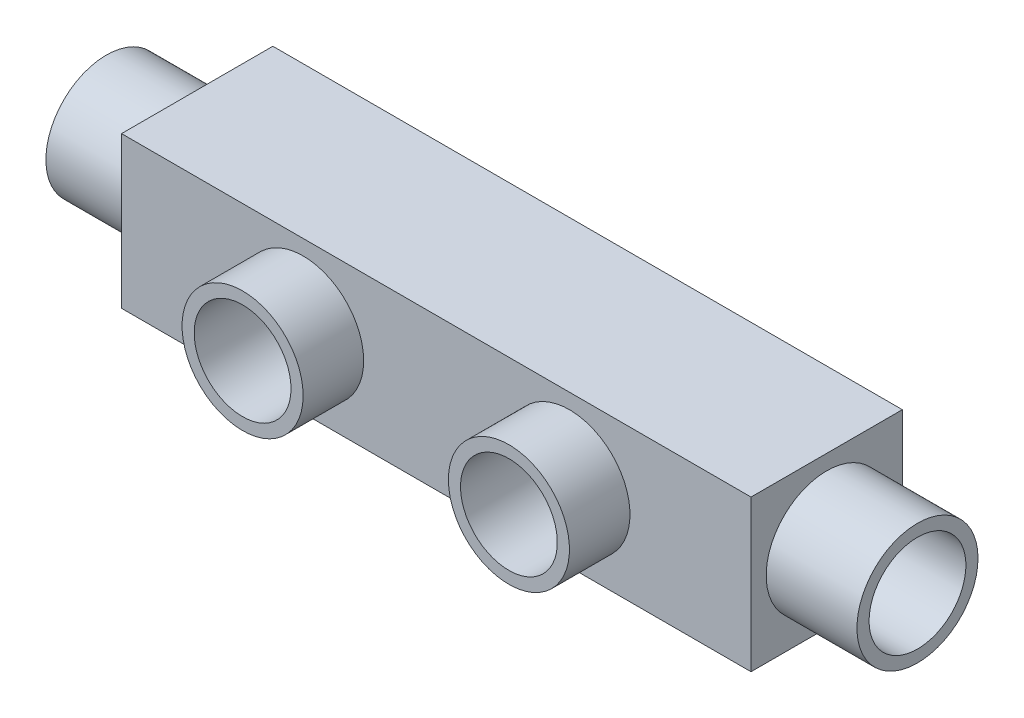
from build123d import *

# Parameters (mm, degrees)
SZKIC1_W                    = 52
SZKIC1_H                    = 25
DODANIE_WYCI_GNI_CIE1_DEPTH = 25
SZKIC1_3_R                  = 10
DODANIE_WYCI_GNI_CIE2_DEPTH = 35
SZKIC2_R                    = 10
DODANIE_WYCI_GNI_CIE3_DEPTH = 15
SZKIC3_R                    = 8
WYTNIJ_WYCI_GNI_CIE1_DEPTH  = 50
SZKIC4_R                    = 8
WYTNIJ_WYCI_GNI_CIE2_DEPTH  = 31


with BuildPart() as part:
    # Szkic1 → Dodanie-wyci_gni_cie1 (new body)
    with BuildSketch(Plane.XY):
        with Locations((26, 12.5)):
            Rectangle(SZKIC1_W, SZKIC1_H)
    extrude(amount=DODANIE_WYCI_GNI_CIE1_DEPTH)

    # Szkic1_3 → Dodanie-wyci_gni_cie2 (add)
    with BuildSketch(Plane.XY):
        with Locations((30, 12.5)):
            Circle(SZKIC1_3_R)
    extrude(amount=DODANIE_WYCI_GNI_CIE2_DEPTH)

    # Szkic2 → Dodanie-wyci_gni_cie3 (add)
    with BuildSketch(Plane(origin=(0, 0, 0), x_dir=(0, 0, -1), z_dir=(1, 0, 0))):
        with Locations((-12.5, 12.5)):
            Circle(SZKIC2_R)
    extrude(amount=-DODANIE_WYCI_GNI_CIE3_DEPTH)

    # Szkic3 → Wytnij-wyci_gni_cie1 (cut)
    with BuildSketch(Plane.ZY.offset(15)):
        with Locations((12.5, 12.5)):
            Circle(SZKIC3_R)
    extrude(amount=-WYTNIJ_WYCI_GNI_CIE1_DEPTH, mode=Mode.SUBTRACT)

    # Szkic4 → Wytnij-wyci_gni_cie2 (cut)
    with BuildSketch(Plane.XY.offset(35)):
        with Locations((30, 12.5)):
            Circle(SZKIC4_R)
    extrude(amount=-WYTNIJ_WYCI_GNI_CIE2_DEPTH, mode=Mode.SUBTRACT)

    # Lustro1: part across plane


with BuildPart() as part_1:
    add(part.part)
    add(part.part.mirror(Plane(origin=(52, 0, 25), x_dir=(0, 0, 1), z_dir=(1, 0, 0))))


solid = part_1.part
